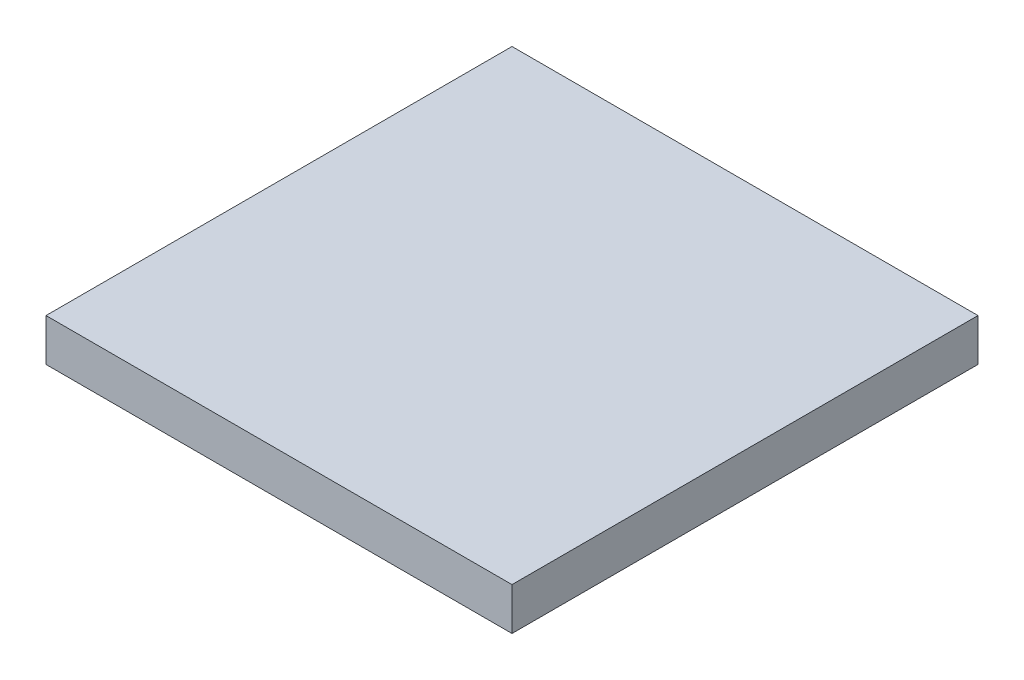
from build123d import *

# Parameters (mm, degrees)
SKETCH2_W           = 16.5
SKETCH2_H           = 16.5
BOSS_EXTRUDE1_DEPTH = 1.5


with BuildPart() as part:
    # Sketch2 → Boss-Extrude1 (new body)
    with BuildSketch(Plane(origin=(0, 0, 0), x_dir=(1, 0, 0), z_dir=(0, 1, 0))):
        with Locations((0, -8.25)):
            Rectangle(SKETCH2_W, SKETCH2_H)
    extrude(amount=BOSS_EXTRUDE1_DEPTH)


solid = part.part
